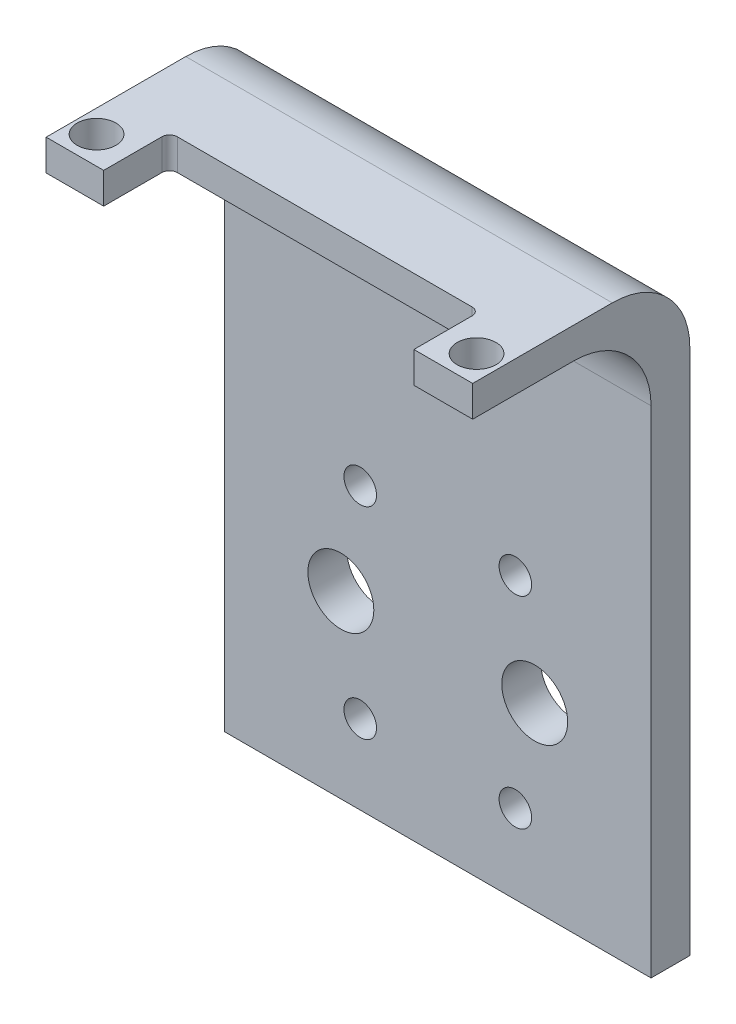
from build123d import *

# Parameters (mm, degrees)
SKETCH1_R               = 4.25
SKETCH1_R_2             = 2.1
BOSS_EXTRUDE1_DEPTH     = 5
SKETCH2_W               = 23
SKETCH2_H               = 60
CUT_EXTRUDE1_DEPTH      = 10
FILLET1_R               = 5
FILLET2_R               = 5
ESQUISSE1_W             = 61.110635513
ESQUISSE1_H             = 10.431484261
ENL_V_MAT_EXTRU_1_DEPTH = 10
ESQUISSE5_W             = 55
ESQUISSE5_H             = 5
BOSS_EXTRU_3_DEPTH      = 20
BOSS_EXTRU_3_DEPTH_BACK = 9
ESQUISSE6_W             = 55
ESQUISSE6_H             = 28
BOSS_EXTRU_4_DEPTH      = 4
CONG_2_R                = 10
ESQUISSE11_R            = 2.5
ENL_V_MAT_EXTRU_2_DEPTH = 4


with BuildPart() as part:
    # Sketch1 → Boss-Extrude1 (new body)
    with BuildSketch(Plane.XY):
        with BuildLine():
            Line((-50.417601538, -29.831415105), (-27.417601538, -29.831415105))
            ThreePointArc((-27.417601538, -29.831415105), (0.082398462, -23.727510052), (27.582398462, -29.831415105))
            Line((27.582398462, -29.831415105), (50.582398462, -29.831415105))
            Line((50.582398462, -29.831415105), (50.582398462, 25.168584895))
            ThreePointArc((50.582398462, 25.168584895), (49.117932367, 28.704118801), (45.582398462, 30.168584895))
            Line((45.582398462, 30.168584895), (-45.417601538, 30.168584895))
            ThreePointArc((-45.417601538, 30.168584895), (-48.953135444, 28.704118801), (-50.417601538, 25.168584895))
            Line((-50.417601538, 25.168584895), (-50.417601538, -29.831415105))
        make_face()
        with Locations((12.582398462, -0.519851907)):
            Circle(SKETCH1_R, mode=Mode.SUBTRACT)
        with Locations((10.082398462, -13.519851907)):
            Circle(SKETCH1_R_2, mode=Mode.SUBTRACT)
        with Locations((-9.917601538, -13.519851907)):
            Circle(SKETCH1_R_2, mode=Mode.SUBTRACT)
        with Locations((-12.417601538, -0.519851907)):
            Circle(SKETCH1_R, mode=Mode.SUBTRACT)
        with Locations((-9.917601538, 12.480148093)):
            Circle(SKETCH1_R_2, mode=Mode.SUBTRACT)
        with Locations((10.082398462, 12.480148093)):
            Circle(SKETCH1_R_2, mode=Mode.SUBTRACT)
    extrude(amount=BOSS_EXTRUDE1_DEPTH)

    # Sketch2 → Cut-Extrude1 (cut)
    with BuildSketch(Plane.XY.offset(5)):
        with Locations((-38.917601538, 0.168584895)):
            Rectangle(SKETCH2_W, SKETCH2_H)
        with Locations((39.082398462, 0.168584895)):
            Rectangle(SKETCH2_W, SKETCH2_H)
    extrude(amount=-CUT_EXTRUDE1_DEPTH, mode=Mode.SUBTRACT)

    # Fillet1
    fillet1_edges = [part.edges().sort_by_distance(p)[0] for p in [
        (27.582398462, 30.168584895, 2.5),
    ]]
    fillet(fillet1_edges, radius=FILLET1_R)

    # Fillet2
    fillet2_edges = [part.edges().sort_by_distance(p)[0] for p in [
        (-27.417601538, 30.168584895, 2.5),
    ]]
    fillet(fillet2_edges, radius=FILLET2_R)

    # Esquisse1 → Enlèv. mat.-Extru.1 (cut)
    with BuildSketch(Plane.XY.offset(5)):
        with Locations((0.082398462, -28.943252183)):
            Rectangle(ESQUISSE1_W, ESQUISSE1_H)
    extrude(amount=-ENL_V_MAT_EXTRU_1_DEPTH, mode=Mode.SUBTRACT)

    # Esquisse5 → Boss.-Extru.3 (add, two sides)
    with BuildSketch(Plane(origin=(0, 30.168584895, 0), x_dir=(1, 0, 0), z_dir=(0, 1, 0))) as boss_extru_3_sk:
        with Locations((0.082398462, -2.5)):
            Rectangle(ESQUISSE5_W, ESQUISSE5_H)
    extrude(amount=BOSS_EXTRU_3_DEPTH)
    extrude(boss_extru_3_sk.sketch, amount=-BOSS_EXTRU_3_DEPTH_BACK)

    # Esquisse6 → Boss.-Extru.4 (add)
    with BuildSketch(Plane(origin=(0, 50.168584895, 0), x_dir=(1, 0, 0), z_dir=(0, 1, 0))):
        with Locations((0.082398462, -14)):
            Rectangle(ESQUISSE6_W, ESQUISSE6_H)
    extrude(amount=BOSS_EXTRU_4_DEPTH)

    # Congé2
    cong_2_edges = [part.edges().sort_by_distance(p)[0] for p in [
        (0.082398462, 50.168584895, 5),
        (0.082398462, 54.168584895, 0),
    ]]
    fillet(cong_2_edges, radius=CONG_2_R)

    # Esquisse11 → Enlèv. mat.-Extru.2 (cut)
    with BuildSketch(Plane(origin=(0, 54.168584895, 0), x_dir=(1, 0, 0), z_dir=(0, 1, 0))):
        with Locations((-24.5, -24.42)):
            Circle(ESQUISSE11_R)
        with Locations((24.5, -24.42)):
            Circle(ESQUISSE11_R)
        with BuildLine():
            Line((-19, -19.5), (19, -19.5))
            ThreePointArc((19, -19.5), (19.707106781, -19.792893219), (20, -20.5))
            Line((20, -20.5), (20, -40.5))
            Line((20, -40.5), (-20, -40.5))
            Line((-20, -40.5), (-20, -20.5))
            ThreePointArc((-20, -20.5), (-19.707106781, -19.792893219), (-19, -19.5))
        make_face()
    extrude(amount=-ENL_V_MAT_EXTRU_2_DEPTH, mode=Mode.SUBTRACT)


solid = part.part
